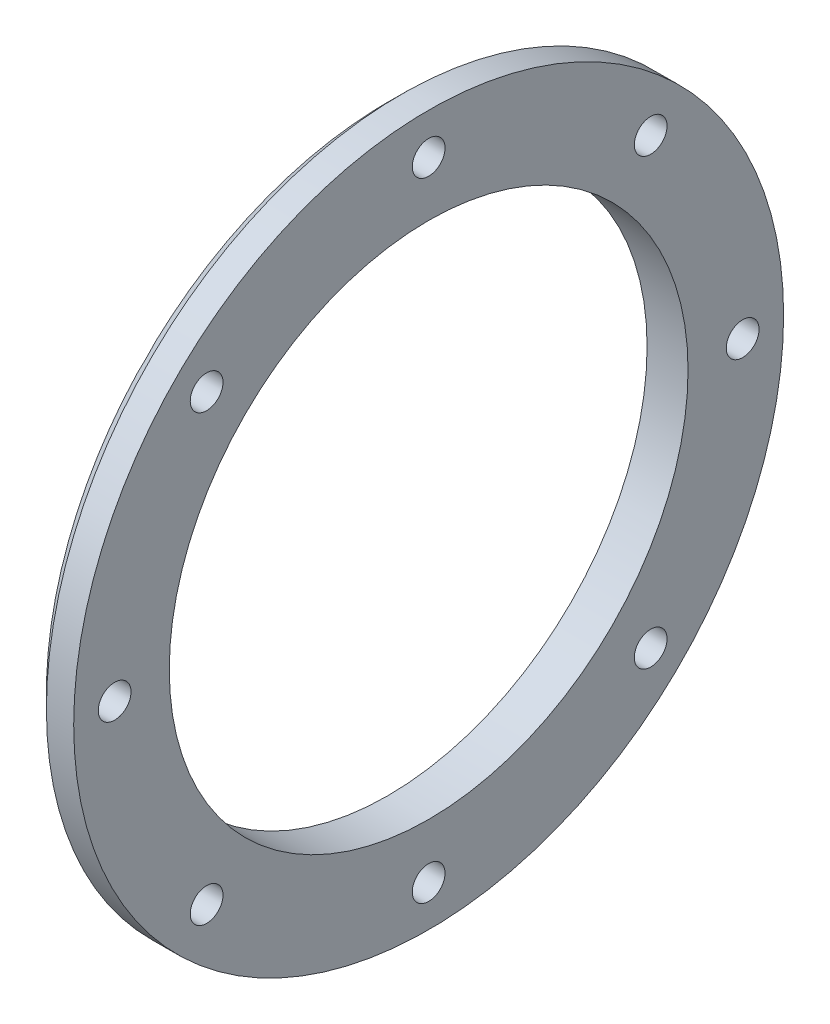
from build123d import *

# Parameters (mm, degrees)
HOLE_WIZARD_M21_D           = 2.4
HOLE_WIZARD_M21_CSINK_D     = 4.4
HOLE_WIZARD_M21_CSINK_ANGLE = 90
PATTERN_CIRCULAR_1_COUNT    = 8


with BuildPart() as part:
    # Эскиз1 → Повернуть1 (revolve)
    with BuildSketch(Plane.XY):
        Polygon((0, 19), (0, 25), (1, 26), (3, 26), (3, 19), align=None)
    revolve(axis=Axis((0, 0, 0), (1, 0, 0)))

    # Зенковка для винта с потайной головкой M21 (through all)
    with Locations(Plane.ZY):
        with Locations((16.263455967, 16.263455967)):
            hole_wizard_m21 = CounterSinkHole(HOLE_WIZARD_M21_D / 2, HOLE_WIZARD_M21_CSINK_D / 2, counter_sink_angle=HOLE_WIZARD_M21_CSINK_ANGLE)

    # Круговой массив1: Зенковка для винта с потайной головкой M21 ×8 about axis
    pattern_circular_1_axis = Axis((0, 0, 0), (1, 0, 0))
    for i in range(1, PATTERN_CIRCULAR_1_COUNT):
        add(hole_wizard_m21.rotate(pattern_circular_1_axis, i * 360 / PATTERN_CIRCULAR_1_COUNT), mode=Mode.SUBTRACT)


solid = part.part
